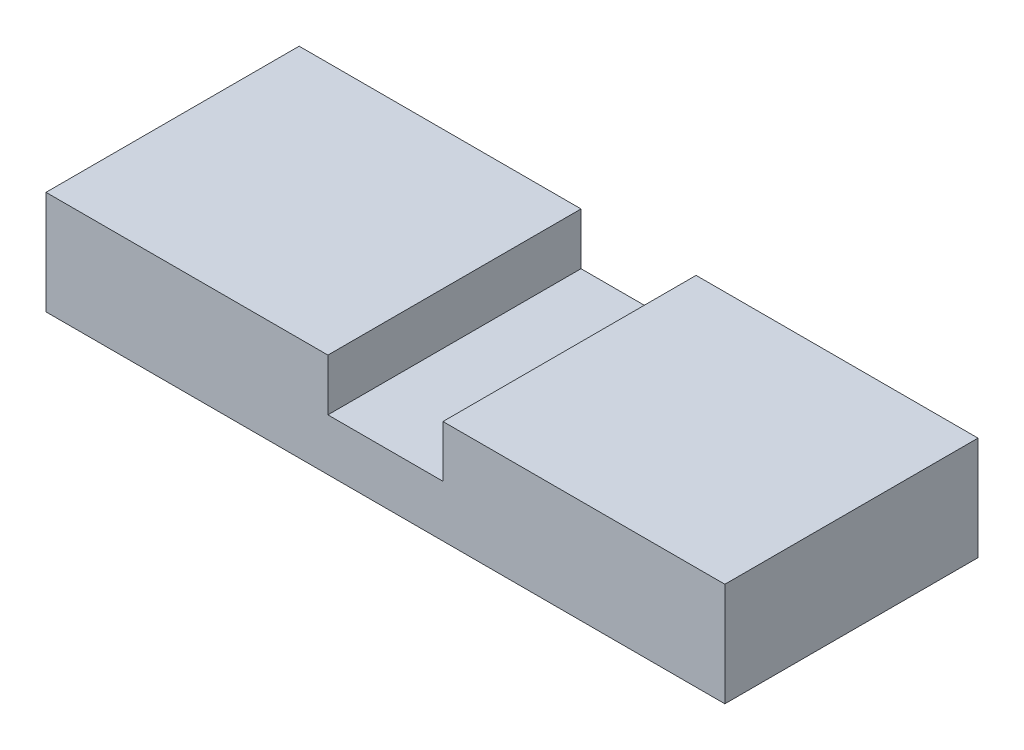
from build123d import *

# Parameters (mm, degrees)
SKETCH1_W      = 118
SKETCH1_H      = 44
EXTRUDE1_DEPTH = 9
SKETCH24_W     = 20
SKETCH24_H     = 44
EXTRUDE4_DEPTH = 9


with BuildPart() as part:
    # Sketch1 → Extrude1 (new body, symmetric)
    with BuildSketch(Plane(origin=(0, 0, 0), x_dir=(1, 0, 0), z_dir=(0, 1, 0))):
        Rectangle(SKETCH1_W, SKETCH1_H)
    extrude(amount=EXTRUDE1_DEPTH, both=True)

    # Sketch24 → Extrude4 (cut)
    with BuildSketch(Plane(origin=(0, 9, 0), x_dir=(1, 0, 0), z_dir=(0, 1, 0))):
        Rectangle(SKETCH24_W, SKETCH24_H)
    extrude(amount=-EXTRUDE4_DEPTH, mode=Mode.SUBTRACT)


solid = part.part
